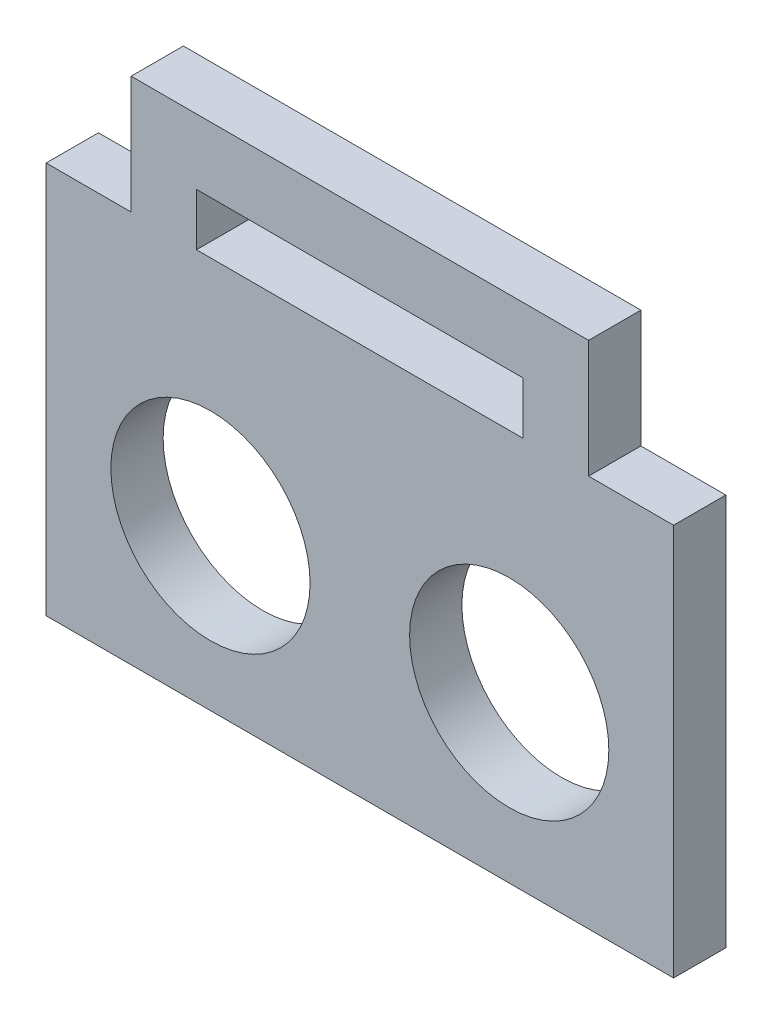
from build123d import *

# Parameters (mm, degrees)
SKICA1_R                = 7.62
P_IDAT_VYSUNUT_M1_DEPTH = 4


with BuildPart() as part:
    # Skica1 → Přidat vysunutím1 (new body)
    with BuildSketch(Plane.XY):
        Polygon((-13.243861265, 5.499663067), (-19.743861265, 5.499663067), (-19.743861265, -24.500336933), (28.256138735, -24.500336933), (28.256138735, 5.499663067), (21.756138735, 5.499663067), (16.756138735, 5.499663067), (-8.243861265, 5.499663067), align=None)
        with Locations((-7.173861265, -12.250168466)):
            Circle(SKICA1_R, mode=Mode.SUBTRACT)
        with Locations((15.683146952, -11.880336933)):
            Circle(SKICA1_R, mode=Mode.SUBTRACT)
        Polygon((-13.243861265, 14.499663067), (-13.243861265, 5.499663067), (-8.243861265, 5.499663067), (-8.243861265, 9.499663067), (16.756138735, 9.499663067), (16.756138735, 5.499663067), (21.756138735, 5.499663067), (21.756138735, 14.499663067), align=None)
    extrude(amount=P_IDAT_VYSUNUT_M1_DEPTH)


solid = part.part
